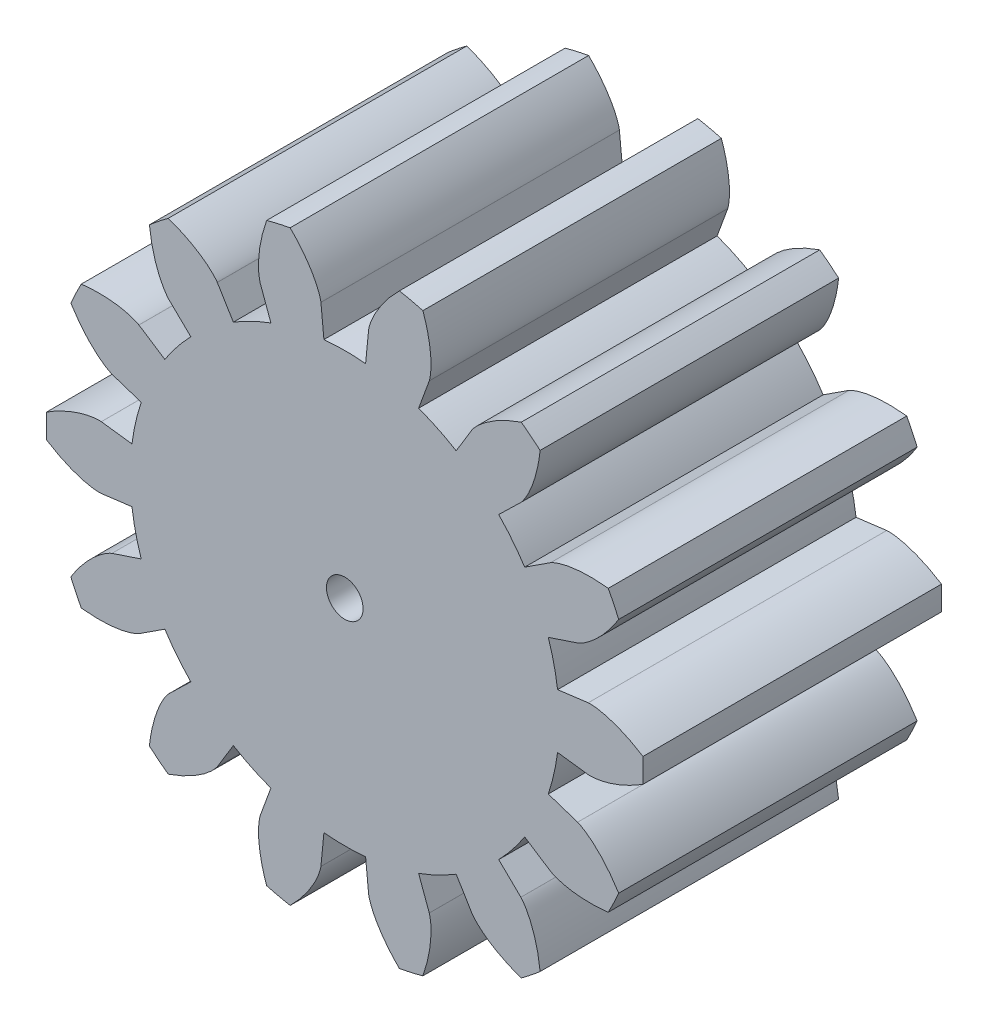
from build123d import *

# Parameters (mm, degrees)
SKETCH1_R           = 1.226754984
BOSS_EXTRUDE1_DEPTH = 20


with BuildPart() as part:
    # Sketch1 → Boss-Extrude1 (new body)
    with BuildSketch(Plane.XY):
        with BuildLine():
            Line((11.800114707, -11.45350812), (10.315023394, -10.012038623))
            ThreePointArc((10.315023394, -10.012038623), (11.23882756, -8.962665902), (12.056324551, -7.828516036))
            Line((12.056324551, -7.828516036), (13.792117304, -8.955615871))
            Line((13.792117304, -8.955615871), (13.793501847, -8.956496469))
            add(Edge.make_bspline(
                [(13.793501847, -8.956496469), (13.794037594, -8.956837067), (13.795341613, -8.957653641), (13.797994076, -8.959283339), (13.80293321, -8.96227664), (13.812877677, -8.968107922), (13.82728351, -8.976270583), (13.855981301, -8.99189351), (13.91832984, -9.023758583), (14.024116954, -9.072248497), (14.180787415, -9.134523851), (14.399080086, -9.206838654), (14.652005206, -9.275332054), (14.900506753, -9.330619965), (15.163365879, -9.377492854), (15.429624644, -9.414372084), (15.699136726, -9.441893924), (15.96519533, -9.460076755), (16.237554604, -9.470191416), (16.501903612, -9.472162597), (16.74682007, -9.467236155), (17.025408847, -9.455080413), (17.258751612, -9.438398757), (17.433179848, -9.422421148), (17.560574989, -9.408878183), (17.654437599, -9.397916421)],
                knots=[0, 0, 0, 0, 0, 0, 0.0125, 0.025, 0.0375, 0.05, 0.075, 0.095833333, 0.158333333, 0.258333333, 0.325, 0.395833333, 0.4625, 0.525, 0.583333333, 0.641666667, 0.695833333, 0.75, 0.795833333, 0.85, 0.891666667, 0.920833333, 1, 1, 1, 1, 1, 1], degree=5, weights=[1, 1, 1, 1, 1, 1, 1, 1, 1, 1, 1, 1, 1, 1, 1, 1, 1, 1, 1, 1, 1, 1, 1, 1, 1, 1]))
            ThreePointArc((17.654437599, -9.397916421), (18.019377358, -8.677674782), (18.354948728, -7.943290073))
            add(Edge.make_bspline(
                [(18.354948728, -7.943290073), (18.34706155, -7.930623869), (18.320741459, -7.88850815), (18.275831094, -7.817506558), (18.185428253, -7.677521202), (18.053649332, -7.481683845), (17.887421793, -7.248027289), (17.70007529, -7.001177083), (17.491948011, -6.746384076), (17.29478551, -6.521329927), (17.104040508, -6.318149994), (16.923591812, -6.138472264), (16.754152987, -5.980739768), (16.596465897, -5.843140593), (16.450917854, -5.72413703), (16.320352256, -5.623865373), (16.202152416, -5.538539674), (16.096472487, -5.466751608), (16.00292481, -5.406919636), (15.921371357, -5.357746324), (15.851323964, -5.317981734), (15.792222076, -5.28627118), (15.743320249, -5.26150979), (15.70515409, -5.243177014), (15.673828949, -5.228890796), (15.650098056, -5.218589388), (15.633515624, -5.211737121), (15.619069354, -5.205983508), (15.610416977, -5.202724861), (15.606049007, -5.201133181), (15.603779291, -5.200322797), (15.602578646, -5.199909789)],
                knots=[0, 0, 0, 0, 0, 0, 0.0125, 0.041666667, 0.070833333, 0.141666667, 0.204166667, 0.266666667, 0.325, 0.383333333, 0.4375, 0.491666667, 0.541666667, 0.5875, 0.633333333, 0.675, 0.7125, 0.75, 0.783333333, 0.816666667, 0.845833333, 0.870833333, 0.895833333, 0.916666667, 0.933333333, 0.954166667, 0.966666667, 0.975, 1, 1, 1, 1, 1, 1], degree=5, weights=[1, 1, 1, 1, 1, 1, 1, 1, 1, 1, 1, 1, 1, 1, 1, 1, 1, 1, 1, 1, 1, 1, 1, 1, 1, 1, 1, 1, 1, 1, 1, 1]))
            Line((15.602578646, -5.199909789), (15.601026918, -5.199376354))
            Line((15.601026918, -5.199376354), (13.637575703, -4.545014184))
            ThreePointArc((13.637575703, -4.545014184), (14.014588738, -3.198738426), (14.259038891, -1.822206054))
            Line((14.259038891, -1.822206054), (16.311964414, -2.084555666))
            Line((16.311964414, -2.084555666), (16.313593921, -2.084748327))
            add(Edge.make_bspline(
                [(16.313593921, -2.084748327), (16.314224392, -2.084822744), (16.315753571, -2.084992659), (16.318850457, -2.085310105), (16.324599207, -2.085863966), (16.336088961, -2.086803027), (16.352609814, -2.087906874), (16.385244164, -2.08953114), (16.455243994, -2.091188561), (16.571593876, -2.088977156), (16.739769347, -2.077108545), (16.967820464, -2.047548291), (17.225416296, -1.999518615), (17.473296979, -1.941510522), (17.730462252, -1.869691236), (17.986354409, -1.787392925), (18.241117683, -1.695252335), (18.488717438, -1.596195999), (18.738493251, -1.487136733), (18.977518741, -1.37421597), (19.196043341, -1.26351213), (19.441768978, -1.131685045), (19.644765646, -1.015411761), (19.794987631, -0.925334858), (19.903890615, -0.857858388), (19.983701774, -0.807256721)],
                knots=[0, 0, 0, 0, 0, 0, 0.0125, 0.025, 0.0375, 0.05, 0.075, 0.095833333, 0.158333333, 0.258333333, 0.325, 0.395833333, 0.4625, 0.525, 0.583333333, 0.641666667, 0.695833333, 0.75, 0.795833333, 0.85, 0.891666667, 0.920833333, 1, 1, 1, 1, 1, 1], degree=5, weights=[1, 1, 1, 1, 1, 1, 1, 1, 1, 1, 1, 1, 1, 1, 1, 1, 1, 1, 1, 1, 1, 1, 1, 1, 1, 1]))
            ThreePointArc((19.983701774, -0.807256721), (20, 0), (19.983701774, 0.807256721))
            add(Edge.make_bspline(
                [(19.983701774, 0.807256721), (19.971100012, 0.815246458), (19.929113104, 0.841771551), (19.857843827, 0.886255897), (19.715656311, 0.973154022), (19.511956962, 1.092420652), (19.260811344, 1.23081451), (18.984913687, 1.371932259), (18.686846945, 1.511189784), (18.411562335, 1.628410963), (18.151550556, 1.728708602), (17.911012654, 1.812298889), (17.689915983, 1.880894206), (17.48814278, 1.936448914), (17.305374812, 1.980516491), (17.144233032, 2.014207842), (17.000717222, 2.039798652), (16.874355223, 2.058624662), (16.764111558, 2.071942591), (16.669298936, 2.080861496), (16.588935206, 2.086295729), (16.521927551, 2.089222603), (16.467124962, 2.090314137), (16.424784148, 2.090271721), (16.390362614, 2.08955169), (16.364512205, 2.088536489), (16.346598862, 2.08751532), (16.331086824, 2.086431145), (16.321877428, 2.085612959), (16.317251419, 2.085151822), (16.314854863, 2.084897161), (16.313593921, 2.084748327)],
                knots=[0, 0, 0, 0, 0, 0, 0.0125, 0.041666667, 0.070833333, 0.141666667, 0.204166667, 0.266666667, 0.325, 0.383333333, 0.4375, 0.491666667, 0.541666667, 0.5875, 0.633333333, 0.675, 0.7125, 0.75, 0.783333333, 0.816666667, 0.845833333, 0.870833333, 0.895833333, 0.916666667, 0.933333333, 0.954166667, 0.966666667, 0.975, 1, 1, 1, 1, 1, 1], degree=5, weights=[1, 1, 1, 1, 1, 1, 1, 1, 1, 1, 1, 1, 1, 1, 1, 1, 1, 1, 1, 1, 1, 1, 1, 1, 1, 1, 1, 1, 1, 1, 1, 1]))
            Line((16.313593921, 2.084748327), (16.311964414, 2.084555666))
            Line((16.311964414, 2.084555666), (14.259038891, 1.822206054))
            ThreePointArc((14.259038891, 1.822206054), (14.014588738, 3.198738426), (13.637575703, 4.545014184))
            Line((13.637575703, 4.545014184), (15.601026918, 5.199376354))
            Line((15.601026918, 5.199376354), (15.602578646, 5.199909789))
            add(Edge.make_bspline(
                [(15.602578646, 5.199909789), (15.603178969, 5.200116293), (15.604630435, 5.200626691), (15.607558367, 5.20168437), (15.612978124, 5.203679648), (15.623737478, 5.207818801), (15.639101193, 5.213992398), (15.669208469, 5.226688499), (15.732995264, 5.255567001), (15.836863392, 5.308041731), (15.98323466, 5.391703582), (16.175875903, 5.517284122), (16.387122433, 5.672324007), (16.585286442, 5.832138891), (16.785823128, 6.008425663), (16.980666095, 6.193601324), (17.170221571, 6.387154769), (17.350322307, 6.583830951), (17.528043497, 6.790463619), (17.694403539, 6.995910983), (17.843254805, 7.190465968), (18.007448324, 7.415854425), (18.139892916, 7.608689988), (18.236155344, 7.75502535), (18.304996599, 7.863070783), (18.354948728, 7.943290073)],
                knots=[0, 0, 0, 0, 0, 0, 0.0125, 0.025, 0.0375, 0.05, 0.075, 0.095833333, 0.158333333, 0.258333333, 0.325, 0.395833333, 0.4625, 0.525, 0.583333333, 0.641666667, 0.695833333, 0.75, 0.795833333, 0.85, 0.891666667, 0.920833333, 1, 1, 1, 1, 1, 1], degree=5, weights=[1, 1, 1, 1, 1, 1, 1, 1, 1, 1, 1, 1, 1, 1, 1, 1, 1, 1, 1, 1, 1, 1, 1, 1, 1, 1]))
            ThreePointArc((18.354948728, 7.943290073), (18.019377358, 8.677674782), (17.654437599, 9.397916421))
            add(Edge.make_bspline(
                [(17.654437599, 9.397916421), (17.639617187, 9.399647226), (17.590279483, 9.405328072), (17.506767049, 9.414484502), (17.340956841, 9.431084157), (17.105682217, 9.450157842), (16.81936099, 9.4658784), (16.509557093, 9.473313592), (16.180586662, 9.469453974), (15.881703436, 9.455625091), (15.603923404, 9.433175258), (15.350937775, 9.404122019), (15.121974165, 9.369994014), (14.916078506, 9.332500965), (14.732290053, 9.292904431), (14.572488196, 9.253342491), (14.432081483, 9.214129838), (14.310064956, 9.17626507), (14.204960413, 9.140431176), (14.115667424, 9.107329177), (14.040904381, 9.077356736), (13.979262646, 9.050920227), (13.929413621, 9.028125713), (13.891284269, 9.009716507), (13.860583949, 8.994132837), (13.837734014, 8.9820021), (13.822037718, 8.973309751), (13.808532261, 8.965602522), (13.800589879, 8.960869554), (13.796622069, 8.958446934), (13.79457334, 8.957177665), (13.793501847, 8.956496469)],
                knots=[0, 0, 0, 0, 0, 0, 0.0125, 0.041666667, 0.070833333, 0.141666667, 0.204166667, 0.266666667, 0.325, 0.383333333, 0.4375, 0.491666667, 0.541666667, 0.5875, 0.633333333, 0.675, 0.7125, 0.75, 0.783333333, 0.816666667, 0.845833333, 0.870833333, 0.895833333, 0.916666667, 0.933333333, 0.954166667, 0.966666667, 0.975, 1, 1, 1, 1, 1, 1], degree=5, weights=[1, 1, 1, 1, 1, 1, 1, 1, 1, 1, 1, 1, 1, 1, 1, 1, 1, 1, 1, 1, 1, 1, 1, 1, 1, 1, 1, 1, 1, 1, 1, 1]))
            Line((13.793501847, 8.956496469), (13.792117304, 8.955615871))
            Line((13.792117304, 8.955615871), (12.056324551, 7.828516036))
            ThreePointArc((12.056324551, 7.828516036), (11.23882756, 8.962665902), (10.315023394, 10.012038623))
            Line((10.315023394, 10.012038623), (11.800114707, 11.45350812))
            Line((11.800114707, 11.45350812), (11.801281317, 11.454661999))
            add(Edge.make_bspline(
                [(11.801281317, 11.454661999), (11.80173259, 11.455108522), (11.802818863, 11.456198143), (11.804997929, 11.45842146), (11.809015242, 11.462570688), (11.816913174, 11.470968245), (11.828076779, 11.48319653), (11.849693866, 11.507698379), (11.89463387, 11.561393064), (11.965447888, 11.653737853), (12.061024326, 11.79262269), (12.180100735, 11.989350749), (12.303157997, 12.220693294), (12.412356521, 12.45066167), (12.516545867, 12.69650017), (12.611748606, 12.947876871), (12.698552497, 13.204507538), (12.775483055, 13.459849436), (12.845949761, 13.723129371), (12.906694709, 13.980411968), (12.956390821, 14.220284095), (13.006531684, 14.494592977), (13.042191923, 14.72579737), (13.065428839, 14.899407678), (13.080573511, 15.02662235), (13.090772978, 15.12057085)],
                knots=[0, 0, 0, 0, 0, 0, 0.0125, 0.025, 0.0375, 0.05, 0.075, 0.095833333, 0.158333333, 0.258333333, 0.325, 0.395833333, 0.4625, 0.525, 0.583333333, 0.641666667, 0.695833333, 0.75, 0.795833333, 0.85, 0.891666667, 0.920833333, 1, 1, 1, 1, 1, 1], degree=5, weights=[1, 1, 1, 1, 1, 1, 1, 1, 1, 1, 1, 1, 1, 1, 1, 1, 1, 1, 1, 1, 1, 1, 1, 1, 1, 1]))
            ThreePointArc((13.090772978, 15.12057085), (12.469796037, 15.636629649), (11.82849554, 16.127203516))
            add(Edge.make_bspline(
                [(11.82849554, 16.127203516), (11.814391843, 16.122332581), (11.767475281, 16.106044019), (11.688260351, 16.078058991), (11.531668195, 16.02107241), (11.311417322, 15.936175373), (11.046629916, 15.826108981), (10.764280241, 15.698388985), (10.46956275, 15.552176669), (10.206278394, 15.410036703), (9.965747851, 15.269285864), (9.750421404, 15.13334345), (9.558939906, 15.003251593), (9.389701951, 14.880136745), (9.241294569, 14.764718678), (9.114483353, 14.659739176), (9.004995008, 14.563489606), (8.911490823, 14.476433642), (8.832342646, 14.398545267), (8.766254862, 14.329978621), (8.711900242, 14.270535916), (8.66783333, 14.219972097), (8.63281108, 14.177806268), (8.606445176, 14.144676441), (8.585546643, 14.11731567), (8.570222892, 14.096472038), (8.559852488, 14.081830135), (8.551028533, 14.069026363), (8.545926252, 14.061316037), (8.543402514, 14.057411763), (8.542107388, 14.055379281), (8.541437567, 14.054300641)],
                knots=[0, 0, 0, 0, 0, 0, 0.0125, 0.041666667, 0.070833333, 0.141666667, 0.204166667, 0.266666667, 0.325, 0.383333333, 0.4375, 0.491666667, 0.541666667, 0.5875, 0.633333333, 0.675, 0.7125, 0.75, 0.783333333, 0.816666667, 0.845833333, 0.870833333, 0.895833333, 0.916666667, 0.933333333, 0.954166667, 0.966666667, 0.975, 1, 1, 1, 1, 1, 1], degree=5, weights=[1, 1, 1, 1, 1, 1, 1, 1, 1, 1, 1, 1, 1, 1, 1, 1, 1, 1, 1, 1, 1, 1, 1, 1, 1, 1, 1, 1, 1, 1, 1, 1]))
            Line((8.541437567, 14.054300641), (8.540572214, 14.052906519))
            Line((8.540572214, 14.052906519), (7.465707272, 12.284292406))
            ThreePointArc((7.465707272, 12.284292406), (6.23707875, 12.951427476), (4.949454195, 13.496056023))
            Line((4.949454195, 13.496056023), (5.662045059, 15.439132136))
            Line((5.662045059, 15.439132136), (5.662595489, 15.440677917))
            add(Edge.make_bspline(
                [(5.662595489, 15.440677917), (5.662808333, 15.441276021), (5.663314262, 15.442729051), (5.664312872, 15.445677653), (5.666132063, 15.451159025), (5.669604291, 15.462151746), (5.674356698, 15.478012757), (5.683202066, 15.509467463), (5.70039436, 15.57734344), (5.724128684, 15.691268271), (5.749980206, 15.857868247), (5.771907238, 16.086779421), (5.782402231, 16.348604397), (5.781007163, 16.603178207), (5.768213193, 16.869877106), (5.744919634, 17.137666608), (5.711779363, 17.406545646), (5.670302704, 17.669979666), (5.619558129, 17.937761048), (5.562656701, 18.195920903), (5.503354736, 18.433600558), (5.429511929, 18.702499625), (5.361324867, 18.926279983), (5.306933916, 19.092779586), (5.265382416, 19.213967072), (5.233809092, 19.303037129)],
                knots=[0, 0, 0, 0, 0, 0, 0.0125, 0.025, 0.0375, 0.05, 0.075, 0.095833333, 0.158333333, 0.258333333, 0.325, 0.395833333, 0.4625, 0.525, 0.583333333, 0.641666667, 0.695833333, 0.75, 0.795833333, 0.85, 0.891666667, 0.920833333, 1, 1, 1, 1, 1, 1], degree=5, weights=[1, 1, 1, 1, 1, 1, 1, 1, 1, 1, 1, 1, 1, 1, 1, 1, 1, 1, 1, 1, 1, 1, 1, 1, 1, 1]))
            ThreePointArc((5.233809092, 19.303037129), (4.450418679, 19.498558244), (3.659774873, 19.662300168))
            add(Edge.make_bspline(
                [(3.659774873, 19.662300168), (3.6491813, 19.651792242), (3.61397828, 19.616760421), (3.554750344, 19.557176712), (3.438391237, 19.437890787), (3.2767875, 19.265837927), (3.085978309, 19.051784584), (2.887005671, 18.814205912), (2.684913533, 18.55460004), (2.509374746, 18.312301555), (2.353733715, 18.08112714), (2.218714492, 17.865220613), (2.102640365, 17.664931191), (2.003579767, 17.480578949), (1.919947358, 17.312199314), (1.8512433, 17.162594726), (1.794358833, 17.028371648), (1.747886641, 16.909366989), (1.710371097, 16.804850881), (1.680578013, 16.714400052), (1.657397416, 16.63726044), (1.639633319, 16.572584098), (1.626374429, 16.519398413), (1.616994064, 16.478109733), (1.61003653, 16.444390997), (1.605274021, 16.418962808), (1.602283493, 16.401271359), (1.599888732, 16.385906988), (1.598637121, 16.376746427), (1.598057313, 16.372133789), (1.597772306, 16.369740652), (1.597636822, 16.368478207)],
                knots=[0, 0, 0, 0, 0, 0, 0.0125, 0.041666667, 0.070833333, 0.141666667, 0.204166667, 0.266666667, 0.325, 0.383333333, 0.4375, 0.491666667, 0.541666667, 0.5875, 0.633333333, 0.675, 0.7125, 0.75, 0.783333333, 0.816666667, 0.845833333, 0.870833333, 0.895833333, 0.916666667, 0.933333333, 0.954166667, 0.966666667, 0.975, 1, 1, 1, 1, 1, 1], degree=5, weights=[1, 1, 1, 1, 1, 1, 1, 1, 1, 1, 1, 1, 1, 1, 1, 1, 1, 1, 1, 1, 1, 1, 1, 1, 1, 1, 1, 1, 1, 1, 1, 1]))
            Line((1.597636822, 16.368478207), (1.597462053, 16.366846683))
            Line((1.597462053, 16.366846683), (1.396415107, 14.307014009))
            ThreePointArc((1.396415107, 14.307014009), (0, 14.375), (-1.396415107, 14.307014009))
            Line((-1.396415107, 14.307014009), (-1.597462053, 16.366846683))
            Line((-1.597462053, 16.366846683), (-1.597636822, 16.368478207))
            add(Edge.make_bspline(
                [(-1.597636822, 16.368478207), (-1.597704564, 16.36910943), (-1.597879183, 16.370638079), (-1.598258818, 16.373727957), (-1.598998061, 16.37945582), (-1.600639255, 16.390866463), (-1.603239319, 16.407218732), (-1.608917603, 16.439396304), (-1.622878164, 16.508009903), (-1.650924409, 16.620950566), (-1.699918012, 16.782268513), (-1.779483276, 16.998024137), (-1.883629213, 17.238473896), (-1.995341563, 17.467231677), (-2.122584847, 17.701967986), (-2.259761129, 17.933131294), (-2.406281724, 18.161003912), (-2.557950639, 18.380353714), (-2.719855909, 18.599599158), (-2.883133687, 18.807504546), (-3.03968825, 18.995916356), (-3.222889252, 19.206146851), (-3.381418331, 19.37818073), (-3.502664354, 19.504592339), (-3.592682242, 19.595749971), (-3.659774873, 19.662300168)],
                knots=[0, 0, 0, 0, 0, 0, 0.0125, 0.025, 0.0375, 0.05, 0.075, 0.095833333, 0.158333333, 0.258333333, 0.325, 0.395833333, 0.4625, 0.525, 0.583333333, 0.641666667, 0.695833333, 0.75, 0.795833333, 0.85, 0.891666667, 0.920833333, 1, 1, 1, 1, 1, 1], degree=5, weights=[1, 1, 1, 1, 1, 1, 1, 1, 1, 1, 1, 1, 1, 1, 1, 1, 1, 1, 1, 1, 1, 1, 1, 1, 1, 1]))
            ThreePointArc((-3.659774873, 19.662300168), (-4.450418679, 19.498558244), (-5.233809092, 19.303037129))
            add(Edge.make_bspline(
                [(-5.233809092, 19.303037129), (-5.238794354, 19.288973435), (-5.255311441, 19.242136838), (-5.282821566, 19.162755732), (-5.335901275, 19.004796503), (-5.406850272, 18.779664999), (-5.485889149, 18.504020596), (-5.562075778, 18.203638616), (-5.631515736, 17.882057315), (-5.684541347, 17.587590499), (-5.72446625, 17.311779434), (-5.752436036, 17.05867173), (-5.770112887, 16.82785452), (-5.779375962, 16.618778107), (-5.781668973, 16.430786556), (-5.778658192, 16.266187906), (-5.771672115, 16.120575846), (-5.761907927, 15.993192824), (-5.750360425, 15.882749681), (-5.737957922, 15.788329565), (-5.725373295, 15.708771492), (-5.71331618, 15.642792568), (-5.702185623, 15.589121105), (-5.692722554, 15.547851302), (-5.684361063, 15.51445301), (-5.677619058, 15.489476627), (-5.672637399, 15.472239641), (-5.668128653, 15.457357774), (-5.665281697, 15.44856134), (-5.663802738, 15.444153927), (-5.663021177, 15.441874126), (-5.662595489, 15.440677917)],
                knots=[0, 0, 0, 0, 0, 0, 0.0125, 0.041666667, 0.070833333, 0.141666667, 0.204166667, 0.266666667, 0.325, 0.383333333, 0.4375, 0.491666667, 0.541666667, 0.5875, 0.633333333, 0.675, 0.7125, 0.75, 0.783333333, 0.816666667, 0.845833333, 0.870833333, 0.895833333, 0.916666667, 0.933333333, 0.954166667, 0.966666667, 0.975, 1, 1, 1, 1, 1, 1], degree=5, weights=[1, 1, 1, 1, 1, 1, 1, 1, 1, 1, 1, 1, 1, 1, 1, 1, 1, 1, 1, 1, 1, 1, 1, 1, 1, 1, 1, 1, 1, 1, 1, 1]))
            Line((-5.662595489, 15.440677917), (-5.662045059, 15.439132136))
            Line((-5.662045059, 15.439132136), (-4.949454195, 13.496056023))
            ThreePointArc((-4.949454195, 13.496056023), (-6.23707875, 12.951427476), (-7.465707272, 12.284292406))
            Line((-7.465707272, 12.284292406), (-8.540572214, 14.052906519))
            Line((-8.540572214, 14.052906519), (-8.541437567, 14.054300641))
            add(Edge.make_bspline(
                [(-8.541437567, 14.054300641), (-8.541772477, 14.054839961), (-8.54259306, 14.056141462), (-8.544275747, 14.058760629), (-8.547427009, 14.06360051), (-8.553856566, 14.073169056), (-8.563294126, 14.086773816), (-8.582371409, 14.113301092), (-8.624719764, 14.169062548), (-8.698991675, 14.258649759), (-8.81312662, 14.38273468), (-8.978425303, 14.542601706), (-9.17658479, 14.714052224), (-9.376488421, 14.871685691), (-9.592978926, 15.027967006), (-9.816868486, 15.176719392), (-10.047749204, 15.318452623), (-10.279570488, 15.45027329), (-10.520569128, 15.577558545), (-10.75788409, 15.694031254), (-10.980683698, 15.795857951), (-11.236957691, 15.905781146), (-11.454430158, 15.991995125), (-11.618516992, 16.053281372), (-11.739172121, 16.096354262), (-11.82849554, 16.127203516)],
                knots=[0, 0, 0, 0, 0, 0, 0.0125, 0.025, 0.0375, 0.05, 0.075, 0.095833333, 0.158333333, 0.258333333, 0.325, 0.395833333, 0.4625, 0.525, 0.583333333, 0.641666667, 0.695833333, 0.75, 0.795833333, 0.85, 0.891666667, 0.920833333, 1, 1, 1, 1, 1, 1], degree=5, weights=[1, 1, 1, 1, 1, 1, 1, 1, 1, 1, 1, 1, 1, 1, 1, 1, 1, 1, 1, 1, 1, 1, 1, 1, 1, 1]))
            ThreePointArc((-11.82849554, 16.127203516), (-12.469796037, 15.636629649), (-13.090772978, 15.12057085))
            add(Edge.make_bspline(
                [(-13.090772978, 15.12057085), (-13.089162536, 15.105736876), (-13.083722279, 15.056372065), (-13.074065874, 14.972915964), (-13.053353099, 14.807569193), (-13.019595038, 14.573949101), (-12.971208981, 14.291308392), (-12.909519905, 13.98761744), (-12.832554249, 13.66775383), (-12.752564309, 13.379441446), (-12.668865469, 13.113621497), (-12.584246057, 12.8734437), (-12.500024516, 12.657814882), (-12.417655402, 12.465424445), (-12.338154857, 12.29505501), (-12.264025559, 12.148063079), (-12.194552616, 12.019902292), (-12.130485965, 11.909370677), (-12.072162541, 11.814875116), (-12.020020919, 11.735186776), (-11.974163608, 11.668967694), (-11.93467334, 11.614754124), (-11.90135788, 11.571227174), (-11.874925653, 11.538150239), (-11.852901234, 11.511687332), (-11.835990051, 11.492109635), (-11.824022883, 11.478741108), (-11.813503644, 11.46728928), (-11.807121995, 11.460599215), (-11.803877194, 11.45726997), (-11.802183864, 11.455555046), (-11.801281317, 11.454661999)],
                knots=[0, 0, 0, 0, 0, 0, 0.0125, 0.041666667, 0.070833333, 0.141666667, 0.204166667, 0.266666667, 0.325, 0.383333333, 0.4375, 0.491666667, 0.541666667, 0.5875, 0.633333333, 0.675, 0.7125, 0.75, 0.783333333, 0.816666667, 0.845833333, 0.870833333, 0.895833333, 0.916666667, 0.933333333, 0.954166667, 0.966666667, 0.975, 1, 1, 1, 1, 1, 1], degree=5, weights=[1, 1, 1, 1, 1, 1, 1, 1, 1, 1, 1, 1, 1, 1, 1, 1, 1, 1, 1, 1, 1, 1, 1, 1, 1, 1, 1, 1, 1, 1, 1, 1]))
            Line((-11.801281317, 11.454661999), (-11.800114707, 11.45350812))
            Line((-11.800114707, 11.45350812), (-10.315023394, 10.012038623))
            ThreePointArc((-10.315023394, 10.012038623), (-11.23882756, 8.962665902), (-12.056324551, 7.828516036))
            Line((-12.056324551, 7.828516036), (-13.792117304, 8.955615871))
            Line((-13.792117304, 8.955615871), (-13.793501847, 8.956496469))
            add(Edge.make_bspline(
                [(-13.793501847, 8.956496469), (-13.794037594, 8.956837067), (-13.795341613, 8.957653641), (-13.797994076, 8.959283339), (-13.80293321, 8.96227664), (-13.812877677, 8.968107922), (-13.82728351, 8.976270583), (-13.855981301, 8.99189351), (-13.91832984, 9.023758583), (-14.024116954, 9.072248497), (-14.180787415, 9.134523851), (-14.399080086, 9.206838654), (-14.652005206, 9.275332054), (-14.900506753, 9.330619965), (-15.163365879, 9.377492854), (-15.429624644, 9.414372084), (-15.699136726, 9.441893924), (-15.96519533, 9.460076755), (-16.237554604, 9.470191416), (-16.501903612, 9.472162597), (-16.74682007, 9.467236155), (-17.025408847, 9.455080413), (-17.258751613, 9.438398757), (-17.433179848, 9.422421148), (-17.560574989, 9.408878183), (-17.654437599, 9.397916421)],
                knots=[0, 0, 0, 0, 0, 0, 0.0125, 0.025, 0.0375, 0.05, 0.075, 0.095833333, 0.158333333, 0.258333333, 0.325, 0.395833333, 0.4625, 0.525, 0.583333333, 0.641666667, 0.695833333, 0.75, 0.795833333, 0.85, 0.891666667, 0.920833333, 1, 1, 1, 1, 1, 1], degree=5, weights=[1, 1, 1, 1, 1, 1, 1, 1, 1, 1, 1, 1, 1, 1, 1, 1, 1, 1, 1, 1, 1, 1, 1, 1, 1, 1]))
            ThreePointArc((-17.654437599, 9.397916421), (-18.019377358, 8.677674782), (-18.354948728, 7.943290073))
            add(Edge.make_bspline(
                [(-18.354948728, 7.943290073), (-18.34706155, 7.930623869), (-18.320741459, 7.88850815), (-18.275831094, 7.817506558), (-18.185428253, 7.677521202), (-18.053649332, 7.481683845), (-17.887421793, 7.248027289), (-17.70007529, 7.001177083), (-17.491948011, 6.746384076), (-17.294785511, 6.521329927), (-17.104040508, 6.318149994), (-16.923591812, 6.138472264), (-16.754152987, 5.980739768), (-16.596465897, 5.843140593), (-16.450917854, 5.72413703), (-16.320352256, 5.623865373), (-16.202152416, 5.538539674), (-16.096472487, 5.466751608), (-16.00292481, 5.406919636), (-15.921371357, 5.357746324), (-15.851323964, 5.317981734), (-15.792222076, 5.28627118), (-15.743320249, 5.26150979), (-15.70515409, 5.243177014), (-15.673828949, 5.228890796), (-15.650098056, 5.218589388), (-15.633515624, 5.211737121), (-15.619069354, 5.205983508), (-15.610416977, 5.202724861), (-15.606049007, 5.201133181), (-15.603779291, 5.200322797), (-15.602578646, 5.199909789)],
                knots=[0, 0, 0, 0, 0, 0, 0.0125, 0.041666667, 0.070833333, 0.141666667, 0.204166667, 0.266666667, 0.325, 0.383333333, 0.4375, 0.491666667, 0.541666667, 0.5875, 0.633333333, 0.675, 0.7125, 0.75, 0.783333333, 0.816666667, 0.845833333, 0.870833333, 0.895833333, 0.916666667, 0.933333333, 0.954166667, 0.966666667, 0.975, 1, 1, 1, 1, 1, 1], degree=5, weights=[1, 1, 1, 1, 1, 1, 1, 1, 1, 1, 1, 1, 1, 1, 1, 1, 1, 1, 1, 1, 1, 1, 1, 1, 1, 1, 1, 1, 1, 1, 1, 1]))
            Line((-15.602578646, 5.199909789), (-15.601026918, 5.199376354))
            Line((-15.601026918, 5.199376354), (-13.637575703, 4.545014184))
            ThreePointArc((-13.637575703, 4.545014184), (-14.014588738, 3.198738426), (-14.259038891, 1.822206054))
            Line((-14.259038891, 1.822206054), (-16.311964414, 2.084555666))
            Line((-16.311964414, 2.084555666), (-16.313593921, 2.084748327))
            add(Edge.make_bspline(
                [(-16.313593921, 2.084748327), (-16.314224392, 2.084822744), (-16.315753571, 2.084992659), (-16.318850457, 2.085310105), (-16.324599207, 2.085863966), (-16.336088961, 2.086803027), (-16.352609814, 2.087906874), (-16.385244164, 2.08953114), (-16.455243994, 2.091188561), (-16.571593876, 2.088977156), (-16.739769347, 2.077108545), (-16.967820464, 2.047548291), (-17.225416296, 1.999518615), (-17.473296979, 1.941510522), (-17.730462252, 1.869691236), (-17.986354409, 1.787392925), (-18.241117683, 1.695252335), (-18.488717438, 1.596195999), (-18.738493251, 1.487136733), (-18.977518741, 1.37421597), (-19.196043341, 1.26351213), (-19.441768978, 1.131685045), (-19.644765646, 1.015411761), (-19.794987631, 0.925334858), (-19.903890615, 0.857858388), (-19.983701774, 0.807256721)],
                knots=[0, 0, 0, 0, 0, 0, 0.0125, 0.025, 0.0375, 0.05, 0.075, 0.095833333, 0.158333333, 0.258333333, 0.325, 0.395833333, 0.4625, 0.525, 0.583333333, 0.641666667, 0.695833333, 0.75, 0.795833333, 0.85, 0.891666667, 0.920833333, 1, 1, 1, 1, 1, 1], degree=5, weights=[1, 1, 1, 1, 1, 1, 1, 1, 1, 1, 1, 1, 1, 1, 1, 1, 1, 1, 1, 1, 1, 1, 1, 1, 1, 1]))
            ThreePointArc((-19.983701774, 0.807256721), (-20, 0), (-19.983701774, -0.807256721))
            add(Edge.make_bspline(
                [(-19.983701774, -0.807256721), (-19.971100012, -0.815246458), (-19.929113104, -0.841771551), (-19.857843827, -0.886255897), (-19.715656311, -0.973154022), (-19.511956962, -1.092420652), (-19.260811344, -1.23081451), (-18.984913687, -1.371932259), (-18.686846945, -1.511189784), (-18.411562335, -1.628410963), (-18.151550556, -1.728708602), (-17.911012654, -1.812298889), (-17.689915983, -1.880894206), (-17.48814278, -1.936448914), (-17.305374812, -1.980516491), (-17.144233032, -2.014207842), (-17.000717222, -2.039798652), (-16.874355223, -2.058624662), (-16.764111558, -2.071942591), (-16.669298936, -2.080861496), (-16.588935206, -2.086295729), (-16.521927551, -2.089222603), (-16.467124962, -2.090314137), (-16.424784148, -2.090271721), (-16.390362614, -2.08955169), (-16.364512205, -2.088536489), (-16.346598862, -2.08751532), (-16.331086824, -2.086431145), (-16.321877428, -2.085612959), (-16.317251419, -2.085151822), (-16.314854863, -2.084897161), (-16.313593921, -2.084748327)],
                knots=[0, 0, 0, 0, 0, 0, 0.0125, 0.041666667, 0.070833333, 0.141666667, 0.204166667, 0.266666667, 0.325, 0.383333333, 0.4375, 0.491666667, 0.541666667, 0.5875, 0.633333333, 0.675, 0.7125, 0.75, 0.783333333, 0.816666667, 0.845833333, 0.870833333, 0.895833333, 0.916666667, 0.933333333, 0.954166667, 0.966666667, 0.975, 1, 1, 1, 1, 1, 1], degree=5, weights=[1, 1, 1, 1, 1, 1, 1, 1, 1, 1, 1, 1, 1, 1, 1, 1, 1, 1, 1, 1, 1, 1, 1, 1, 1, 1, 1, 1, 1, 1, 1, 1]))
            Line((-16.313593921, -2.084748327), (-16.311964414, -2.084555666))
            Line((-16.311964414, -2.084555666), (-14.259038891, -1.822206054))
            ThreePointArc((-14.259038891, -1.822206054), (-14.014588738, -3.198738426), (-13.637575703, -4.545014184))
            Line((-13.637575703, -4.545014184), (-15.601026918, -5.199376354))
            Line((-15.601026918, -5.199376354), (-15.602578646, -5.199909789))
            add(Edge.make_bspline(
                [(-15.602578646, -5.199909789), (-15.603178969, -5.200116293), (-15.604630435, -5.200626691), (-15.607558367, -5.20168437), (-15.612978124, -5.203679648), (-15.623737478, -5.207818801), (-15.639101193, -5.213992398), (-15.669208469, -5.226688499), (-15.732995264, -5.255567001), (-15.836863392, -5.308041731), (-15.98323466, -5.391703582), (-16.175875903, -5.517284122), (-16.387122433, -5.672324008), (-16.585286442, -5.83213889), (-16.785823128, -6.008425663), (-16.980666095, -6.193601324), (-17.170221571, -6.387154769), (-17.350322307, -6.583830951), (-17.528043497, -6.790463619), (-17.694403539, -6.995910983), (-17.843254805, -7.190465968), (-18.007448324, -7.415854425), (-18.139892916, -7.608689988), (-18.236155344, -7.75502535), (-18.304996599, -7.863070783), (-18.354948728, -7.943290073)],
                knots=[0, 0, 0, 0, 0, 0, 0.0125, 0.025, 0.0375, 0.05, 0.075, 0.095833333, 0.158333333, 0.258333333, 0.325, 0.395833333, 0.4625, 0.525, 0.583333333, 0.641666667, 0.695833333, 0.75, 0.795833333, 0.85, 0.891666667, 0.920833333, 1, 1, 1, 1, 1, 1], degree=5, weights=[1, 1, 1, 1, 1, 1, 1, 1, 1, 1, 1, 1, 1, 1, 1, 1, 1, 1, 1, 1, 1, 1, 1, 1, 1, 1]))
            ThreePointArc((-18.354948728, -7.943290073), (-18.019377358, -8.677674782), (-17.654437599, -9.397916421))
            add(Edge.make_bspline(
                [(-17.654437599, -9.397916421), (-17.639617187, -9.399647226), (-17.590279483, -9.405328072), (-17.506767049, -9.414484502), (-17.340956841, -9.431084157), (-17.105682217, -9.450157842), (-16.81936099, -9.4658784), (-16.509557093, -9.473313592), (-16.180586663, -9.469453974), (-15.881703435, -9.455625091), (-15.603923404, -9.433175258), (-15.350937775, -9.404122019), (-15.121974165, -9.369994014), (-14.916078506, -9.332500965), (-14.732290053, -9.292904431), (-14.572488196, -9.253342491), (-14.432081483, -9.214129838), (-14.310064956, -9.17626507), (-14.204960413, -9.140431176), (-14.115667424, -9.107329177), (-14.040904381, -9.077356736), (-13.979262646, -9.050920227), (-13.929413621, -9.028125713), (-13.891284269, -9.009716507), (-13.860583949, -8.994132837), (-13.837734014, -8.9820021), (-13.822037718, -8.973309751), (-13.808532261, -8.965602522), (-13.800589879, -8.960869554), (-13.796622069, -8.958446934), (-13.79457334, -8.957177665), (-13.793501847, -8.956496469)],
                knots=[0, 0, 0, 0, 0, 0, 0.0125, 0.041666667, 0.070833333, 0.141666667, 0.204166667, 0.266666667, 0.325, 0.383333333, 0.4375, 0.491666667, 0.541666667, 0.5875, 0.633333333, 0.675, 0.7125, 0.75, 0.783333333, 0.816666667, 0.845833333, 0.870833333, 0.895833333, 0.916666667, 0.933333333, 0.954166667, 0.966666667, 0.975, 1, 1, 1, 1, 1, 1], degree=5, weights=[1, 1, 1, 1, 1, 1, 1, 1, 1, 1, 1, 1, 1, 1, 1, 1, 1, 1, 1, 1, 1, 1, 1, 1, 1, 1, 1, 1, 1, 1, 1, 1]))
            Line((-13.793501847, -8.956496469), (-13.792117304, -8.955615871))
            Line((-13.792117304, -8.955615871), (-12.056324551, -7.828516036))
            ThreePointArc((-12.056324551, -7.828516036), (-11.23882756, -8.962665902), (-10.315023394, -10.012038623))
            Line((-10.315023394, -10.012038623), (-11.800114707, -11.45350812))
            Line((-11.800114707, -11.45350812), (-11.801281317, -11.454661999))
            add(Edge.make_bspline(
                [(-11.801281317, -11.454661999), (-11.80173259, -11.455108522), (-11.802818863, -11.456198143), (-11.804997929, -11.45842146), (-11.809015242, -11.462570688), (-11.816913174, -11.470968245), (-11.828076779, -11.48319653), (-11.849693866, -11.507698379), (-11.89463387, -11.561393064), (-11.965447888, -11.653737853), (-12.061024326, -11.79262269), (-12.180100735, -11.989350749), (-12.303157997, -12.220693294), (-12.412356521, -12.45066167), (-12.516545867, -12.69650017), (-12.611748606, -12.947876871), (-12.698552497, -13.204507538), (-12.775483055, -13.459849436), (-12.845949761, -13.723129371), (-12.906694709, -13.980411968), (-12.956390821, -14.220284095), (-13.006531684, -14.494592977), (-13.042191923, -14.72579737), (-13.065428839, -14.899407678), (-13.080573511, -15.02662235), (-13.090772978, -15.12057085)],
                knots=[0, 0, 0, 0, 0, 0, 0.0125, 0.025, 0.0375, 0.05, 0.075, 0.095833333, 0.158333333, 0.258333333, 0.325, 0.395833333, 0.4625, 0.525, 0.583333333, 0.641666667, 0.695833333, 0.75, 0.795833333, 0.85, 0.891666667, 0.920833333, 1, 1, 1, 1, 1, 1], degree=5, weights=[1, 1, 1, 1, 1, 1, 1, 1, 1, 1, 1, 1, 1, 1, 1, 1, 1, 1, 1, 1, 1, 1, 1, 1, 1, 1]))
            ThreePointArc((-13.090772978, -15.12057085), (-12.469796037, -15.636629649), (-11.82849554, -16.127203516))
            add(Edge.make_bspline(
                [(-11.82849554, -16.127203516), (-11.814391843, -16.122332581), (-11.767475281, -16.106044019), (-11.688260351, -16.078058991), (-11.531668195, -16.02107241), (-11.311417322, -15.936175373), (-11.046629916, -15.826108981), (-10.764280241, -15.698388985), (-10.46956275, -15.552176669), (-10.206278394, -15.410036703), (-9.965747851, -15.269285864), (-9.750421404, -15.13334345), (-9.558939906, -15.003251593), (-9.389701951, -14.880136745), (-9.241294569, -14.764718678), (-9.114483353, -14.659739176), (-9.004995008, -14.563489606), (-8.911490823, -14.476433642), (-8.832342646, -14.398545267), (-8.766254862, -14.329978621), (-8.711900242, -14.270535916), (-8.66783333, -14.219972097), (-8.63281108, -14.177806268), (-8.606445176, -14.144676441), (-8.585546643, -14.11731567), (-8.570222892, -14.096472038), (-8.559852488, -14.081830135), (-8.551028533, -14.069026363), (-8.545926252, -14.061316037), (-8.543402514, -14.057411763), (-8.542107388, -14.055379281), (-8.541437567, -14.054300641)],
                knots=[0, 0, 0, 0, 0, 0, 0.0125, 0.041666667, 0.070833333, 0.141666667, 0.204166667, 0.266666667, 0.325, 0.383333333, 0.4375, 0.491666667, 0.541666667, 0.5875, 0.633333333, 0.675, 0.7125, 0.75, 0.783333333, 0.816666667, 0.845833333, 0.870833333, 0.895833333, 0.916666667, 0.933333333, 0.954166667, 0.966666667, 0.975, 1, 1, 1, 1, 1, 1], degree=5, weights=[1, 1, 1, 1, 1, 1, 1, 1, 1, 1, 1, 1, 1, 1, 1, 1, 1, 1, 1, 1, 1, 1, 1, 1, 1, 1, 1, 1, 1, 1, 1, 1]))
            Line((-8.541437567, -14.054300641), (-8.540572214, -14.052906519))
            Line((-8.540572214, -14.052906519), (-7.465707272, -12.284292406))
            ThreePointArc((-7.465707272, -12.284292406), (-6.23707875, -12.951427476), (-4.949454195, -13.496056023))
            Line((-4.949454195, -13.496056023), (-5.662045059, -15.439132136))
            Line((-5.662045059, -15.439132136), (-5.662595489, -15.440677917))
            add(Edge.make_bspline(
                [(-5.662595489, -15.440677917), (-5.662808333, -15.441276021), (-5.663314262, -15.442729051), (-5.664312872, -15.445677653), (-5.666132063, -15.451159025), (-5.669604291, -15.462151746), (-5.674356698, -15.478012757), (-5.683202066, -15.509467463), (-5.70039436, -15.57734344), (-5.724128684, -15.691268271), (-5.749980206, -15.857868247), (-5.771907238, -16.086779421), (-5.782402231, -16.348604397), (-5.781007163, -16.603178207), (-5.768213192, -16.869877106), (-5.744919634, -17.137666608), (-5.711779363, -17.406545646), (-5.670302704, -17.669979666), (-5.619558129, -17.937761048), (-5.562656701, -18.195920903), (-5.503354736, -18.433600558), (-5.429511929, -18.702499625), (-5.361324867, -18.926279983), (-5.306933916, -19.092779586), (-5.265382416, -19.213967072), (-5.233809092, -19.303037129)],
                knots=[0, 0, 0, 0, 0, 0, 0.0125, 0.025, 0.0375, 0.05, 0.075, 0.095833333, 0.158333333, 0.258333333, 0.325, 0.395833333, 0.4625, 0.525, 0.583333333, 0.641666667, 0.695833333, 0.75, 0.795833333, 0.85, 0.891666667, 0.920833333, 1, 1, 1, 1, 1, 1], degree=5, weights=[1, 1, 1, 1, 1, 1, 1, 1, 1, 1, 1, 1, 1, 1, 1, 1, 1, 1, 1, 1, 1, 1, 1, 1, 1, 1]))
            ThreePointArc((-5.233809092, -19.303037129), (-4.450418679, -19.498558244), (-3.659774873, -19.662300168))
            add(Edge.make_bspline(
                [(-3.659774873, -19.662300168), (-3.6491813, -19.651792242), (-3.61397828, -19.616760421), (-3.554750344, -19.557176712), (-3.438391237, -19.437890787), (-3.2767875, -19.265837927), (-3.085978309, -19.051784584), (-2.887005671, -18.814205912), (-2.684913533, -18.55460004), (-2.509374746, -18.312301555), (-2.353733715, -18.08112714), (-2.218714492, -17.865220613), (-2.102640365, -17.664931191), (-2.003579767, -17.480578949), (-1.919947358, -17.312199314), (-1.8512433, -17.162594726), (-1.794358833, -17.028371648), (-1.747886641, -16.909366989), (-1.710371097, -16.804850881), (-1.680578013, -16.714400052), (-1.657397416, -16.63726044), (-1.639633319, -16.572584098), (-1.626374429, -16.519398413), (-1.616994064, -16.478109733), (-1.61003653, -16.444390997), (-1.605274021, -16.418962808), (-1.602283493, -16.401271359), (-1.599888732, -16.385906988), (-1.598637121, -16.376746427), (-1.598057313, -16.372133789), (-1.597772306, -16.369740652), (-1.597636822, -16.368478207)],
                knots=[0, 0, 0, 0, 0, 0, 0.0125, 0.041666667, 0.070833333, 0.141666667, 0.204166667, 0.266666667, 0.325, 0.383333333, 0.4375, 0.491666667, 0.541666667, 0.5875, 0.633333333, 0.675, 0.7125, 0.75, 0.783333333, 0.816666667, 0.845833333, 0.870833333, 0.895833333, 0.916666667, 0.933333333, 0.954166667, 0.966666667, 0.975, 1, 1, 1, 1, 1, 1], degree=5, weights=[1, 1, 1, 1, 1, 1, 1, 1, 1, 1, 1, 1, 1, 1, 1, 1, 1, 1, 1, 1, 1, 1, 1, 1, 1, 1, 1, 1, 1, 1, 1, 1]))
            Line((-1.597636822, -16.368478207), (-1.597462053, -16.366846683))
            Line((-1.597462053, -16.366846683), (-1.396415107, -14.307014009))
            ThreePointArc((-1.396415107, -14.307014009), (0, -14.375), (1.396415107, -14.307014009))
            Line((1.396415107, -14.307014009), (1.597462053, -16.366846683))
            Line((1.597462053, -16.366846683), (1.597636822, -16.368478207))
            add(Edge.make_bspline(
                [(1.597636822, -16.368478207), (1.597704564, -16.36910943), (1.597879183, -16.370638079), (1.598258818, -16.373727957), (1.598998061, -16.37945582), (1.600639255, -16.390866463), (1.603239319, -16.407218732), (1.608917603, -16.439396304), (1.622878164, -16.508009903), (1.650924409, -16.620950566), (1.699918012, -16.782268513), (1.779483276, -16.998024137), (1.883629213, -17.238473896), (1.995341563, -17.467231677), (2.122584847, -17.701967986), (2.259761129, -17.933131294), (2.406281724, -18.161003912), (2.557950639, -18.380353714), (2.719855909, -18.599599158), (2.883133687, -18.807504546), (3.03968825, -18.995916356), (3.222889252, -19.206146851), (3.381418331, -19.37818073), (3.502664354, -19.504592339), (3.592682242, -19.595749971), (3.659774873, -19.662300168)],
                knots=[0, 0, 0, 0, 0, 0, 0.0125, 0.025, 0.0375, 0.05, 0.075, 0.095833333, 0.158333333, 0.258333333, 0.325, 0.395833333, 0.4625, 0.525, 0.583333333, 0.641666667, 0.695833333, 0.75, 0.795833333, 0.85, 0.891666667, 0.920833333, 1, 1, 1, 1, 1, 1], degree=5, weights=[1, 1, 1, 1, 1, 1, 1, 1, 1, 1, 1, 1, 1, 1, 1, 1, 1, 1, 1, 1, 1, 1, 1, 1, 1, 1]))
            ThreePointArc((3.659774873, -19.662300168), (4.450418679, -19.498558244), (5.233809092, -19.303037129))
            add(Edge.make_bspline(
                [(5.233809092, -19.303037129), (5.238794354, -19.288973435), (5.255311441, -19.242136838), (5.282821566, -19.162755732), (5.335901275, -19.004796503), (5.406850272, -18.779664999), (5.485889149, -18.504020596), (5.562075778, -18.203638616), (5.631515736, -17.882057315), (5.684541347, -17.587590499), (5.72446625, -17.311779434), (5.752436036, -17.05867173), (5.770112887, -16.82785452), (5.779375962, -16.618778107), (5.781668973, -16.430786556), (5.778658192, -16.266187906), (5.771672115, -16.120575846), (5.761907927, -15.993192824), (5.750360425, -15.882749681), (5.737957922, -15.788329565), (5.725373295, -15.708771492), (5.71331618, -15.642792568), (5.702185623, -15.589121105), (5.692722554, -15.547851302), (5.684361063, -15.51445301), (5.677619058, -15.489476627), (5.672637399, -15.472239641), (5.668128653, -15.457357774), (5.665281697, -15.44856134), (5.663802738, -15.444153927), (5.663021177, -15.441874126), (5.662595489, -15.440677917)],
                knots=[0, 0, 0, 0, 0, 0, 0.0125, 0.041666667, 0.070833333, 0.141666667, 0.204166667, 0.266666667, 0.325, 0.383333333, 0.4375, 0.491666667, 0.541666667, 0.5875, 0.633333333, 0.675, 0.7125, 0.75, 0.783333333, 0.816666667, 0.845833333, 0.870833333, 0.895833333, 0.916666667, 0.933333333, 0.954166667, 0.966666667, 0.975, 1, 1, 1, 1, 1, 1], degree=5, weights=[1, 1, 1, 1, 1, 1, 1, 1, 1, 1, 1, 1, 1, 1, 1, 1, 1, 1, 1, 1, 1, 1, 1, 1, 1, 1, 1, 1, 1, 1, 1, 1]))
            Line((5.662595489, -15.440677917), (5.662045059, -15.439132136))
            Line((5.662045059, -15.439132136), (4.949454195, -13.496056023))
            ThreePointArc((4.949454195, -13.496056023), (6.23707875, -12.951427476), (7.465707272, -12.284292406))
            Line((7.465707272, -12.284292406), (8.540572214, -14.052906519))
            Line((8.540572214, -14.052906519), (8.541437567, -14.054300641))
            add(Edge.make_bspline(
                [(8.541437567, -14.054300641), (8.541772477, -14.054839961), (8.54259306, -14.056141462), (8.544275747, -14.058760629), (8.547427009, -14.06360051), (8.553856566, -14.073169056), (8.563294126, -14.086773816), (8.582371409, -14.113301092), (8.624719764, -14.169062548), (8.698991675, -14.258649759), (8.81312662, -14.38273468), (8.978425303, -14.542601706), (9.17658479, -14.714052224), (9.376488421, -14.871685691), (9.592978926, -15.027967006), (9.816868486, -15.176719392), (10.047749204, -15.318452623), (10.279570488, -15.45027329), (10.520569128, -15.577558545), (10.75788409, -15.694031254), (10.980683698, -15.795857951), (11.236957691, -15.905781146), (11.454430158, -15.991995125), (11.618516992, -16.053281372), (11.739172121, -16.096354262), (11.82849554, -16.127203516)],
                knots=[0, 0, 0, 0, 0, 0, 0.0125, 0.025, 0.0375, 0.05, 0.075, 0.095833333, 0.158333333, 0.258333333, 0.325, 0.395833333, 0.4625, 0.525, 0.583333333, 0.641666667, 0.695833333, 0.75, 0.795833333, 0.85, 0.891666667, 0.920833333, 1, 1, 1, 1, 1, 1], degree=5, weights=[1, 1, 1, 1, 1, 1, 1, 1, 1, 1, 1, 1, 1, 1, 1, 1, 1, 1, 1, 1, 1, 1, 1, 1, 1, 1]))
            ThreePointArc((11.82849554, -16.127203516), (12.469796037, -15.636629649), (13.090772978, -15.12057085))
            add(Edge.make_bspline(
                [(13.090772978, -15.12057085), (13.089162536, -15.105736876), (13.083722279, -15.056372065), (13.074065874, -14.972915964), (13.053353099, -14.807569193), (13.019595038, -14.573949101), (12.971208981, -14.291308392), (12.909519905, -13.98761744), (12.832554249, -13.66775383), (12.752564309, -13.379441446), (12.668865469, -13.113621497), (12.584246057, -12.8734437), (12.500024516, -12.657814882), (12.417655402, -12.465424445), (12.338154857, -12.29505501), (12.264025559, -12.148063079), (12.194552616, -12.019902292), (12.130485965, -11.909370677), (12.072162541, -11.814875116), (12.020020919, -11.735186776), (11.974163608, -11.668967694), (11.93467334, -11.614754124), (11.90135788, -11.571227174), (11.874925653, -11.538150239), (11.852901234, -11.511687332), (11.835990051, -11.492109635), (11.824022883, -11.478741108), (11.813503644, -11.46728928), (11.807121995, -11.460599215), (11.803877194, -11.45726997), (11.802183864, -11.455555046), (11.801281317, -11.454661999)],
                knots=[0, 0, 0, 0, 0, 0, 0.0125, 0.041666667, 0.070833333, 0.141666667, 0.204166667, 0.266666667, 0.325, 0.383333333, 0.4375, 0.491666667, 0.541666667, 0.5875, 0.633333333, 0.675, 0.7125, 0.75, 0.783333333, 0.816666667, 0.845833333, 0.870833333, 0.895833333, 0.916666667, 0.933333333, 0.954166667, 0.966666667, 0.975, 1, 1, 1, 1, 1, 1], degree=5, weights=[1, 1, 1, 1, 1, 1, 1, 1, 1, 1, 1, 1, 1, 1, 1, 1, 1, 1, 1, 1, 1, 1, 1, 1, 1, 1, 1, 1, 1, 1, 1, 1]))
            Line((11.801281317, -11.454661999), (11.800114707, -11.45350812))
        make_face()
        Circle(SKETCH1_R, mode=Mode.SUBTRACT)
    extrude(amount=BOSS_EXTRUDE1_DEPTH)


solid = part.part
